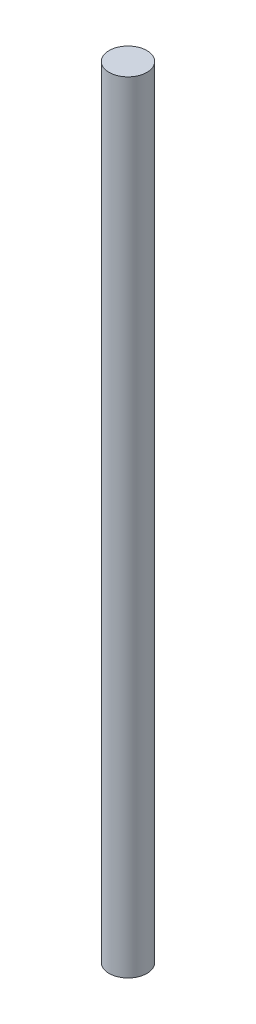
from build123d import *

# Parameters (mm, degrees)
SKETCH1_R               = 6.35
BOSS_EXTRUDE1_DEPTH     = 262
SKETCH2_W               = 3.175
SKETCH2_H               = 3.2004
CUT_EXTRUDE1_DEPTH      = 12.7
CUT_EXTRUDE1_DEPTH_BACK = 12.7


with BuildPart() as part:
    # Sketch1 → Boss-Extrude1 (new body)
    with BuildSketch(Plane(origin=(0, 0, 0), x_dir=(1, 0, 0), z_dir=(0, 1, 0))):
        Circle(SKETCH1_R)
    extrude(amount=BOSS_EXTRUDE1_DEPTH)

    # Sketch2 → Cut-Extrude1 (cut, two sides)
    with BuildSketch(Plane(origin=(0, 131, 0), x_dir=(1, 0, 0), z_dir=(0, 1, 0))) as cut_extrude1_sk:
        with Locations((0, 6.148361062)):
            Rectangle(SKETCH2_W, SKETCH2_H)
    extrude(amount=CUT_EXTRUDE1_DEPTH, mode=Mode.SUBTRACT)
    extrude(cut_extrude1_sk.sketch, amount=-CUT_EXTRUDE1_DEPTH_BACK, mode=Mode.SUBTRACT)


solid = part.part
